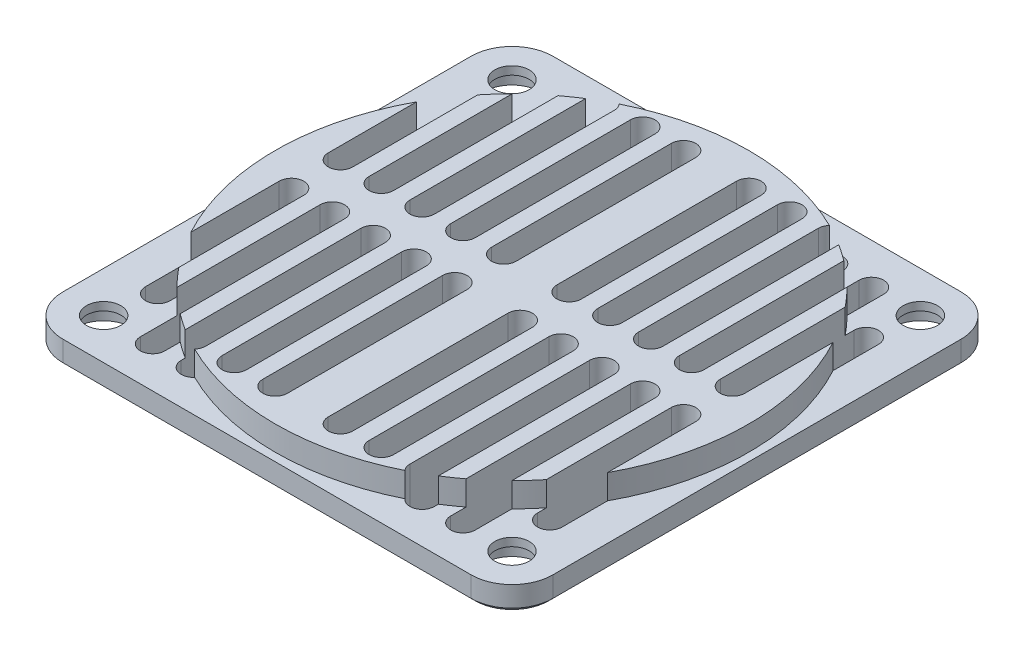
from build123d import *

# Parameters (mm, degrees)
CROQUIS1_W               = 30
CROQUIS1_H               = 30
CROQUIS1_R               = 2.1
SALIENTE_EXTRUIR1_DEPTH  = 6
REDONDEO1_R              = 5
CROQUIS3_R               = 3.45
CORTAR_EXTRUIR2_DEPTH    = 2
REDONDEO1_OF_SIMETR_A1_R = 5
CROQUIS2_OUTSIDE_W       = 79.012
CROQUIS2_OUTSIDE_H       = 79.012
CROQUIS2_OUTSIDE_R       = 29
CORTAR_EXTRUIR1_DEPTH    = 3
CHAFL_N1_SIZE            = 0.5


with BuildPart() as part:
    # Croquis1 → Saliente-Extruir1 (new body)
    with BuildSketch(Plane(origin=(0, 0, 0), x_dir=(1, 0, 0), z_dir=(0, 1, 0))):
        with Locations((15, 15)):
            Rectangle(CROQUIS1_W, CROQUIS1_H)
        with Locations((25, 25)):
            Circle(CROQUIS1_R, mode=Mode.SUBTRACT)
        with BuildLine():
            Line((2.5, 3), (2.5, 25))
            ThreePointArc((2.5, 25), (4, 26.5), (5.5, 25))
            Line((5.5, 25), (5.5, 3))
            ThreePointArc((5.5, 3), (4, 1.5), (2.5, 3))
        make_face(mode=Mode.SUBTRACT)
        with BuildLine():
            Line((7.5, 3), (7.5, 25))
            ThreePointArc((7.5, 25), (9, 26.5), (10.5, 25))
            Line((10.5, 25), (10.5, 3))
            ThreePointArc((10.5, 3), (9, 1.5), (7.5, 3))
        make_face(mode=Mode.SUBTRACT)
        with BuildLine():
            Line((17.5, 3), (17.5, 25))
            ThreePointArc((17.5, 25), (19, 26.5), (20.5, 25))
            Line((20.5, 25), (20.5, 3))
            ThreePointArc((20.5, 3), (19, 1.5), (17.5, 3))
        make_face(mode=Mode.SUBTRACT)
        with BuildLine():
            Line((22.5, 3), (22.5, 19.36981464))
            ThreePointArc((22.5, 19.36981464), (24, 20.86981464), (25.5, 19.36981464))
            Line((25.5, 19.36981464), (25.5, 3))
            ThreePointArc((25.5, 3), (24, 1.5), (22.5, 3))
        make_face(mode=Mode.SUBTRACT)
        with BuildLine():
            Line((15.5, 25), (15.5, 3))
            ThreePointArc((15.5, 3), (14, 1.5), (12.5, 3))
            Line((12.5, 3), (12.5, 25))
            ThreePointArc((12.5, 25), (14, 26.5), (15.5, 25))
        make_face(mode=Mode.SUBTRACT)
    saliente_extruir1 = extrude(amount=SALIENTE_EXTRUIR1_DEPTH)

    # Redondeo1
    redondeo1_edges = [part.edges().sort_by_distance(p)[0] for p in [
        (30, 3, -30),
    ]]
    fillet(redondeo1_edges, radius=REDONDEO1_R)

    # Croquis3 → Cortar-Extruir2 (cut)
    with BuildSketch(Plane.XZ):
        with Locations((25, -25)):
            Circle(CROQUIS3_R)
    cortar_extruir2 = extrude(amount=-CORTAR_EXTRUIR2_DEPTH, mode=Mode.SUBTRACT)

    # Simetría1: Saliente-Extruir1, Cortar-Extruir2 across plane
    add(saliente_extruir1.mirror(Plane(origin=(0, 6, 0), x_dir=(1, 0, 0), z_dir=(0, 0, -1))))
    add(cortar_extruir2.mirror(Plane(origin=(0, 6, 0), x_dir=(1, 0, 0), z_dir=(0, 0, -1))), mode=Mode.SUBTRACT)

    # Redondeo1 of Simetría1
    redondeo1_of_simetr_a1_edges = [part.edges().sort_by_distance(p)[0] for p in [
        (30, 3, 30),
    ]]
    fillet(redondeo1_of_simetr_a1_edges, radius=REDONDEO1_OF_SIMETR_A1_R)

    # Simetría7: part across plane


with BuildPart() as part_1:
    add(part.part)
    add(part.part.mirror(Plane(origin=(0, 6, 0), x_dir=(0, 0, 1), z_dir=(1, 0, 0))))

    # Croquis2 outside → Cortar-Extruir1 (cut)
    with BuildSketch(Plane(origin=(0, 6, 0), x_dir=(1, 0, 0), z_dir=(0, 1, 0))):
        Rectangle(CROQUIS2_OUTSIDE_W, CROQUIS2_OUTSIDE_H)
        Circle(CROQUIS2_OUTSIDE_R, mode=Mode.SUBTRACT)
    extrude(amount=-CORTAR_EXTRUIR1_DEPTH, mode=Mode.SUBTRACT)

    # Chaflán1
    chafl_n1_edges = [part_1.edges().sort_by_distance(p)[0] for p in [
        (30, 0, 0),
        (0, 0, 30),
        (28.535533906, 0, 28.535533906),
        (-30, 0, 0),
        (-28.535533906, 0, -28.535533906),
        (-28.535533906, 0, 28.535533906),
        (0, 0, -30),
        (28.535533906, 0, -28.535533906),
    ]]
    chamfer(chafl_n1_edges, length=CHAFL_N1_SIZE)


solid = part_1.part
